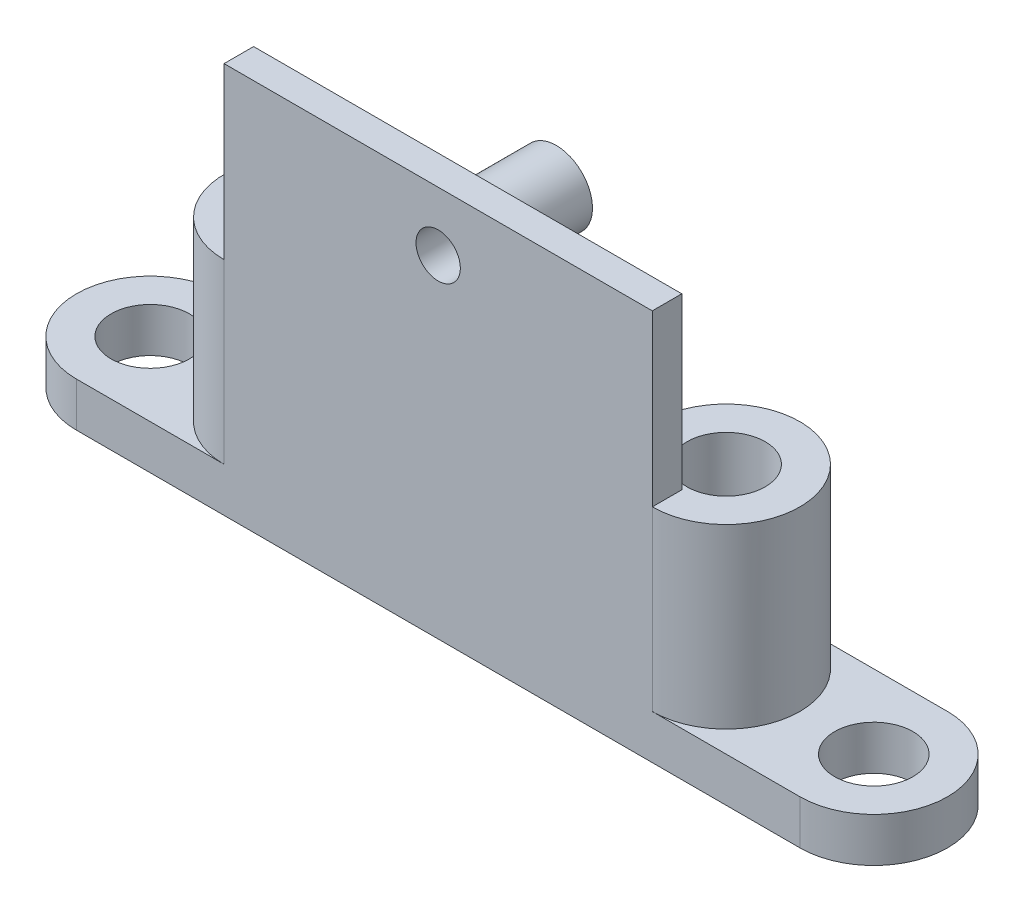
from build123d import *

# Parameters (mm, degrees)
ESQUISSE1_R             = 2.65
BOSS_EXTRU_1_DEPTH      = 15
ESQUISSE2_R             = 3.488871883
ESQUISSE2_R_2           = 3.573781448
BOSS_EXTRU_2_DEPTH      = 4
ENL_V_MAT_EXTRU_1_DEPTH = 5
ESQUISSE8_R             = 2.65
BOSS_EXTRU_3_DEPTH      = 3
ESQUISSE10_W            = 20
ESQUISSE10_H            = 1
BOSS_EXTRU_4_DEPTH      = 12.5
ESQUISSE11_R            = 2.45
ESQUISSE11_R_2          = 1.5
BOSS_EXTRU_5_DEPTH      = 7
ESQUISSE12_W            = 20
ESQUISSE12_H            = 1
BOSS_EXTRU_6_DEPTH      = 4
ESQUISSE13_R            = 3.5
BOSS_EXTRU_7_DEPTH      = 1.5
ESQUISSE14_R            = 1.5
ENL_V_MAT_EXTRU_2_DEPTH = 9
ESQUISSE15_W            = 29
ESQUISSE15_H            = 16.5
ESQUISSE15_R            = 1.5
BOSS_EXTRU_8_DEPTH      = 2
CONG_1_R                = 2


with BuildPart() as part:
    # Esquisse1 → Boss.-Extru.1 (new body)
    with BuildSketch(Plane(origin=(0, 0, 0), x_dir=(1, 0, 0), z_dir=(0, 1, 0))):
        with BuildLine():
            Line((5, 0), (34, 0))
            ThreePointArc((34, 0), (39, 5), (34, 10))
            Line((34, 10), (5, 10))
            ThreePointArc((5, 10), (0, 5), (5, 0))
        make_face()
        with Locations((5, 5)):
            Circle(ESQUISSE1_R, mode=Mode.SUBTRACT)
        with Locations((34, 5)):
            Circle(ESQUISSE1_R, mode=Mode.SUBTRACT)
    extrude(amount=BOSS_EXTRU_1_DEPTH)

    # Esquisse2 → Boss.-Extru.2 (add)
    with BuildSketch(Plane.XZ):
        with Locations((5, -5)):
            Circle(ESQUISSE2_R)
        with Locations((34, -5)):
            Circle(ESQUISSE2_R_2)
    extrude(amount=-BOSS_EXTRU_2_DEPTH)

    # Esquisse3 → Enlèv. mat.-Extru.1 (cut)
    with BuildSketch(Plane(origin=(0, 15, 0), x_dir=(1, 0, 0), z_dir=(0, 1, 0))):
        with BuildLine():
            Line((5, 10), (34, 10))
            ThreePointArc((34, 10), (29, 5), (34, 0))
            Line((34, 0), (5, 0))
            ThreePointArc((5, 0), (10, 5), (5, 10))
        make_face()
    extrude(amount=-ENL_V_MAT_EXTRU_1_DEPTH, mode=Mode.SUBTRACT)

    # Esquisse8 → Boss.-Extru.3 (add)
    with BuildSketch(Plane.XZ):
        with BuildLine():
            Line((44.001861421, -10), (-5.001861421, -10))
            ThreePointArc((-5.001861421, -10), (-10.001861421, -5), (-5.001861421, 0))
            Line((-5.001861421, 0), (44.001861421, 0))
            ThreePointArc((44.001861421, 0), (49.001861421, -5), (44.001861421, -10))
        make_face()
        with Locations((-5.001861421, -5)):
            Circle(ESQUISSE8_R, mode=Mode.SUBTRACT)
        with Locations((44.001861421, -5)):
            Circle(ESQUISSE8_R, mode=Mode.SUBTRACT)
    extrude(amount=-BOSS_EXTRU_3_DEPTH)

    # Esquisse10 → Boss.-Extru.4 (add)
    with BuildSketch(Plane(origin=(0, 10, 0), x_dir=(1, 0, 0), z_dir=(0, 1, 0))):
        with Locations((19.5, 0.5)):
            Rectangle(ESQUISSE10_W, ESQUISSE10_H)
    extrude(amount=BOSS_EXTRU_4_DEPTH)

    # Esquisse11 → Boss.-Extru.5 (add)
    with BuildSketch(Plane(origin=(0, 0, -1), x_dir=(-1, 0, 0), z_dir=(0, 0, -1))):
        with Locations((-19.5, 22.5)):
            Circle(ESQUISSE11_R)
        with Locations((-19.5, 22.5)):
            Circle(ESQUISSE11_R_2, mode=Mode.SUBTRACT)
    extrude(amount=BOSS_EXTRU_5_DEPTH)

    # Esquisse12 → Boss.-Extru.6 (add)
    with BuildSketch(Plane(origin=(0, 22.5, 0), x_dir=(1, 0, 0), z_dir=(0, 1, 0))):
        with Locations((19.5, 0.5)):
            Rectangle(ESQUISSE12_W, ESQUISSE12_H)
    extrude(amount=BOSS_EXTRU_6_DEPTH)

    # Esquisse13 → Boss.-Extru.7 (add)
    with BuildSketch(Plane(origin=(0, 0, -1), x_dir=(-1, 0, 0), z_dir=(0, 0, -1))):
        with Locations((-19.5, 22.5)):
            Circle(ESQUISSE13_R)
    extrude(amount=BOSS_EXTRU_7_DEPTH)

    # Esquisse14 → Enlèv. mat.-Extru.2 (cut, through all)
    with BuildSketch(Plane(origin=(0, 0, -8), x_dir=(-1, 0, 0), z_dir=(0, 0, -1))):
        with Locations((-19.5, 22.5)):
            Circle(ESQUISSE14_R)
    extrude(amount=-ENL_V_MAT_EXTRU_2_DEPTH, mode=Mode.SUBTRACT)

    # Esquisse15 → Boss.-Extru.8 (add)
    with BuildSketch(Plane.XY):
        with Locations((19.5, 18.25)):
            Rectangle(ESQUISSE15_W, ESQUISSE15_H)
        with Locations((19.5, 22.5)):
            Circle(ESQUISSE15_R, mode=Mode.SUBTRACT)
    extrude(amount=-BOSS_EXTRU_8_DEPTH)

    # Congé1
    cong_1_edges = [part.edges().sort_by_distance(p)[0] for p in [
        (19.5, 10, -2),
    ]]
    fillet(cong_1_edges, radius=CONG_1_R)


solid = part.part
